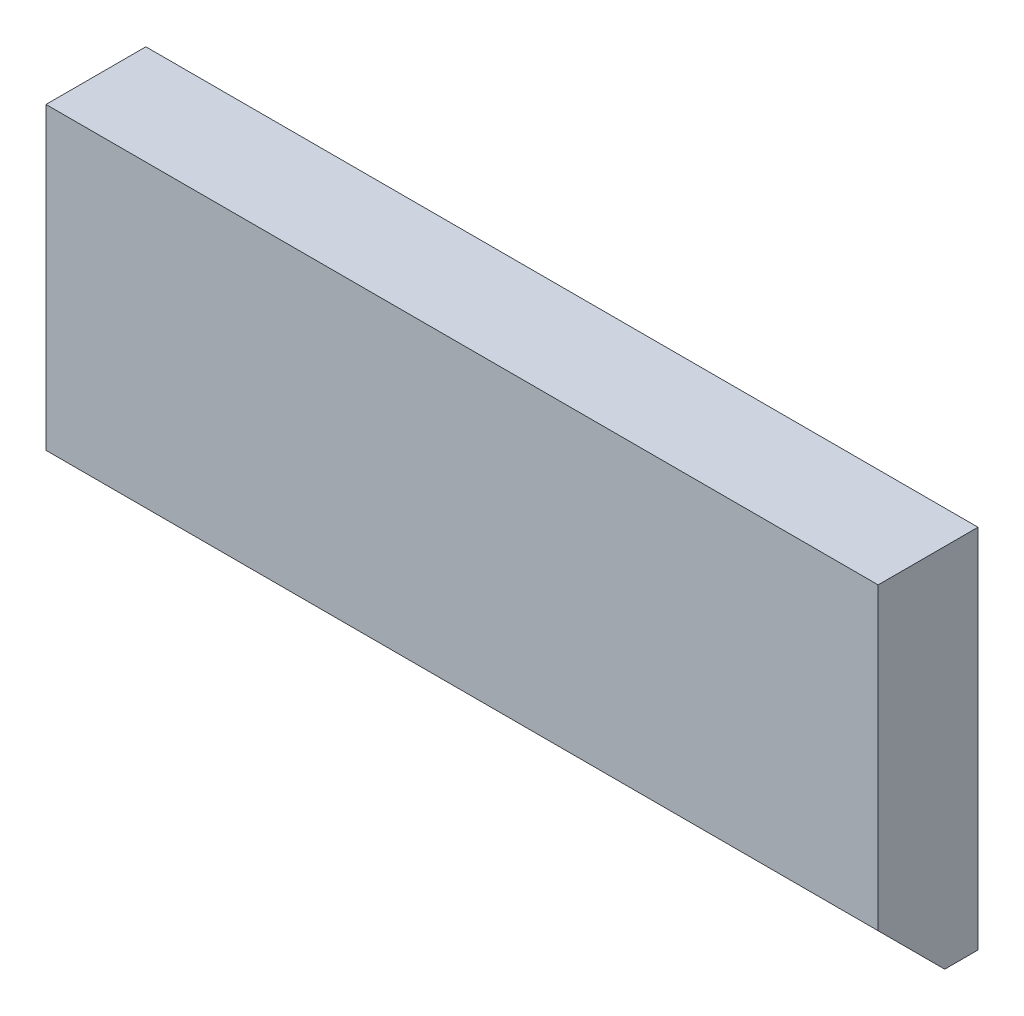
from build123d import *

# Parameters (mm, degrees)
SKETCH_1_W      = 25
SKETCH_1_H      = 11
EXTRUDE_1_DEPTH = 3
CHAMFER_3_SIZE  = 2


with BuildPart() as part:
    # Эскиз1 → Вытянуть1 (new body)
    with BuildSketch(Plane.XY):
        with Locations((-0.5, 0)):
            Rectangle(SKETCH_1_W, SKETCH_1_H)
    extrude(amount=EXTRUDE_1_DEPTH)

    # Фаска3
    chamfer_3_edges = [part.edges().sort_by_distance(p)[0] for p in [
        (-0.5, -5.5, 3),
    ]]
    chamfer(chamfer_3_edges, length=CHAMFER_3_SIZE)


solid = part.part
